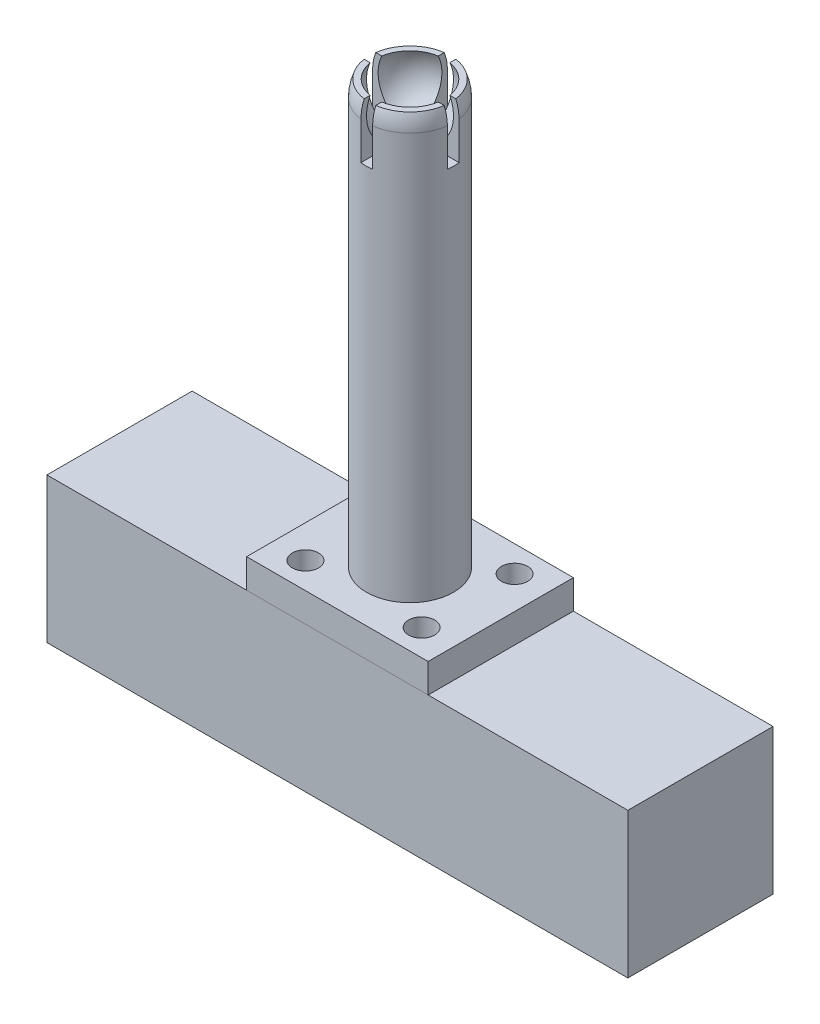
from build123d import *

# Parameters (mm, degrees)
SKETCH1_W           = 101.6
SKETCH1_H           = 25.4
BOSS_EXTRUDE1_DEPTH = 25.4
SKETCH2_W           = 31.75
SKETCH2_H           = 25.4
SKETCH2_R           = 2.286
BOSS_EXTRUDE2_DEPTH = 5.08
SKETCH3_R           = 7.62
BOSS_EXTRUDE3_DEPTH = 63.5
SKETCH5_W           = 2.032
SKETCH5_H           = 7.874
SKETCH5_W_2         = 7.874
SKETCH5_H_2         = 2.032
CUT_EXTRUDE2_DEPTH  = 9.398


with BuildPart() as part:
    # Sketch1 → Boss-Extrude1 (new body)
    with BuildSketch(Plane(origin=(0, 0, 0), x_dir=(1, 0, 0), z_dir=(0, 1, 0))):
        Rectangle(SKETCH1_W, SKETCH1_H)
    extrude(amount=BOSS_EXTRUDE1_DEPTH)


with BuildPart() as body_2:
    # Sketch2 → Boss-Extrude2 (new body)
    with BuildSketch(Plane(origin=(0, 25.4, 0), x_dir=(1, 0, 0), z_dir=(0, 1, 0))):
        Rectangle(SKETCH2_W, SKETCH2_H)
        with Locations(Location((10.16, -8.128, 0), (0, 0, 270))):
            Circle(SKETCH2_R, mode=Mode.SUBTRACT)
        with Locations(Location((-10.16, -8.128, 0), (0, 0, 270))):
            Circle(SKETCH2_R, mode=Mode.SUBTRACT)
        with Locations(Location((-10.16, 8.128, 0), (0, 0, 270))):
            Circle(SKETCH2_R, mode=Mode.SUBTRACT)
        with Locations(Location((10.16, 8.128, 0), (0, 0, 270))):
            Circle(SKETCH2_R, mode=Mode.SUBTRACT)
    extrude(amount=BOSS_EXTRUDE2_DEPTH)

    # Sketch3 → Boss-Extrude3 (add)
    with BuildSketch(Plane(origin=(0, 30.48, 0), x_dir=(1, 0, 0), z_dir=(0, 1, 0))):
        with Locations(Location((0, 0, 0), (0, 0, 270))):
            Circle(SKETCH3_R)
    extrude(amount=BOSS_EXTRUDE3_DEPTH)

    # Sketch4 → Revolve1 (revolve)
    with BuildSketch(Plane.XY, mode=Mode.PRIVATE) as revolve1_sk:
        with BuildLine():
            Line((-7.62, 93.98), (0, 93.98))
            Line((0, 93.98), (0, 94.9325))
            ThreePointArc((0, 94.9325), (-5.623312465, 98.017554861), (-6.04280717, 104.41780726))
            Line((-6.04280717, 104.41780726), (-7.079856089, 104.41780726))
            ThreePointArc((-7.079856089, 104.41780726), (-7.483745833, 103.034555088), (-7.62, 101.6))
            Line((-7.62, 101.6), (-7.62, 93.98))
        make_face()
    revolve(revolve1_sk.sketch.rotate(Axis((0, 93.98, 0), (0, -1, 0)), 270), axis=Axis((0, 93.98, 0), (0, -1, 0)))

    # Sketch5 → Cut-Extrude2 (cut)
    with BuildSketch(Plane(origin=(0, 104.41780726, 0), x_dir=(1, 0, 0), z_dir=(0, 1, 0))):
        with Locations((0, -4.953)):
            Rectangle(SKETCH5_W, SKETCH5_H)
        with Locations((0, 4.953)):
            Rectangle(SKETCH5_W, SKETCH5_H)
        with Locations((4.953, 0)):
            Rectangle(SKETCH5_W_2, SKETCH5_H_2)
        with Locations((-4.953, 0)):
            Rectangle(SKETCH5_W_2, SKETCH5_H_2)
        Rectangle(SKETCH5_W, SKETCH5_H_2)
    extrude(amount=-CUT_EXTRUDE2_DEPTH, mode=Mode.SUBTRACT)


solid = Compound([part.part, body_2.part])
